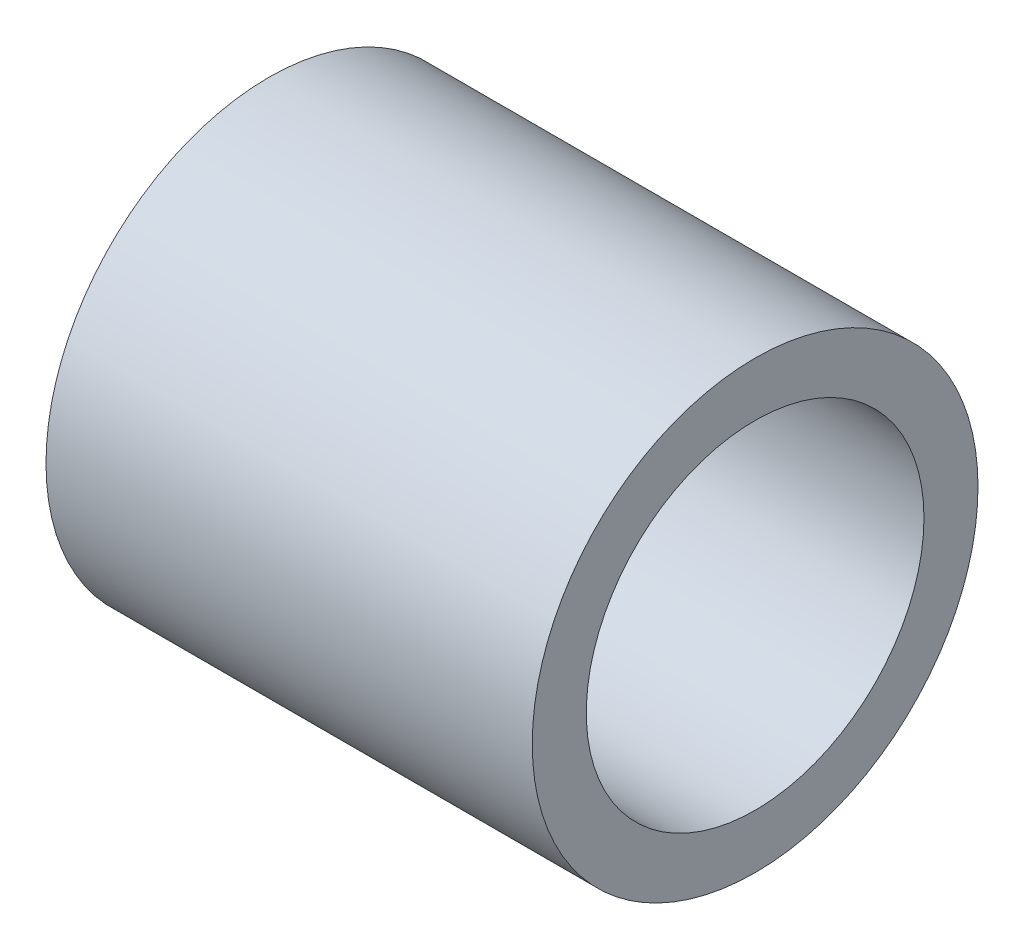
from build123d import *

# Parameters (mm, degrees)
SKETCH1_R                   = 10.4775
BOSS_EXTRUDE1_DEPTH         = 22.86
F_97_0_625_DIAMETER_HOLE1_D = 15.875


with BuildPart() as part:
    # Sketch1 → Boss-Extrude1 (new body)
    with BuildSketch(Plane(origin=(0, 0, 0), x_dir=(0, 0, -1), z_dir=(1, 0, 0))):
        Circle(SKETCH1_R)
    extrude(amount=BOSS_EXTRUDE1_DEPTH)

    # #97 (0.625) Diameter Hole1 (through all)
    with Locations(Plane(origin=(22.86, 0, 0), x_dir=(0, 0, -1), z_dir=(1, 0, 0))):
        with Locations((0, 0)):
            Hole(F_97_0_625_DIAMETER_HOLE1_D / 2)


solid = part.part
